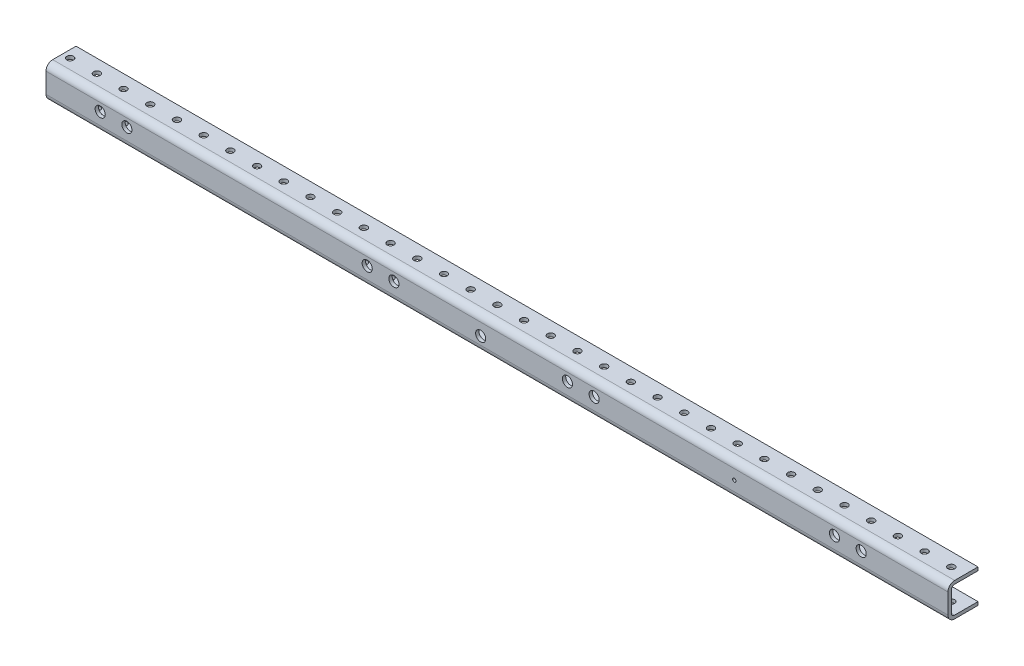
from build123d import *

# Parameters (mm, degrees)
SKETCH1_W          = 889
SKETCH1_H          = 31.75
EXTRUDE1_DEPTH     = 28.575
EXTRUDE2_REACH     = 891.702
SKETCH2_W          = 25.4
SKETCH2_H          = 25.4
HOLE1_D            = 6.35
HOLE1_DEPTH        = 3.175
LPATTERN1_COUNT    = 35
LPATTERN1_PITCH    = 25.4
HOLE2_D            = 9.652
LPATTERN2_COUNT    = 12
LPATTERN2_PITCH    = 25.4
HOLE3_D            = 9.652
HOLE4_D            = 9.652
LPATTERN3_COUNT    = 12
LPATTERN3_PITCH    = 25.4
HOLE5_D            = 3.175
HOLE6_D            = 6.35
LPATTERN4_COUNT    = 35
LPATTERN4_PITCH    = 25.4
FILLET1_R          = 3.175
FILLET2_R          = 3.175
FILLET3_R          = 6.35
FILLET4_R          = 6.35
SKETCH16_W         = 47.760071232
SKETCH16_H         = 71.504803879
CUT_EXTRUDE2_DEPTH = 55


with BuildPart() as part:
    # Sketch1 → Extrude1 (new body)
    with BuildSketch(Plane.XY.offset(3.175)):
        with Locations((428.480011997, 8.672957166)):
            Rectangle(SKETCH1_W, SKETCH1_H)
    extrude(amount=-EXTRUDE1_DEPTH)

    # Sketch2 → Extrude2 (cut, up to next)
    with BuildSketch(Plane.ZY.offset(16.019988003), mode=Mode.PRIVATE) as extrude2_sk1:
        with Locations((-12.7, 8.672957166)):
            Rectangle(SKETCH2_W, SKETCH2_H)
    extrude2_tool1 = extrude(extrude2_sk1.sketch, amount=-EXTRUDE2_REACH, mode=Mode.PRIVATE) & part.part
    add(extrude2_tool1.solids().sort_by_distance((-16.019988, 8.672957, -12.7))[0], mode=Mode.SUBTRACT)

    # Hole1
    with Locations(Plane(origin=(0, 24.547957166, 0), x_dir=(-1, 0, 0), z_dir=(0, 1, 0))):
        with Locations((3.319988003, -12.7)):
            hole1 = Hole(HOLE1_D / 2, depth=HOLE1_DEPTH)

    # LPattern1: Hole1 ×35
    with Locations(*[(i * LPATTERN1_PITCH, 0, 0) for i in range(1, LPATTERN1_COUNT)]):
        add(hole1, mode=Mode.SUBTRACT)

    # Hole2 (through all)
    with Locations(Plane.XY.offset(3.175)):
        with Locations((66.530011997, 10.577957166)):
            hole2 = Hole(HOLE2_D / 2)

    # LPattern2: Hole2 ×12, 8 skipped
    with Locations(*[(i * LPATTERN2_PITCH, 0, 0) for i in range(1, LPATTERN2_COUNT) if i not in (2, 3, 4, 5, 6, 7, 8, 9)]):
        add(hole2, mode=Mode.SUBTRACT)

    # Hole3 (through all)
    with Locations(Plane.XY.offset(3.175)):
        with Locations((428.480011997, 6.767957166)):
            Hole(HOLE3_D / 2)

    # Hole4 (through all)
    with Locations(Plane.XY.offset(3.175)):
        with Locations((511.030011997, 10.577957166)):
            hole4 = Hole(HOLE4_D / 2)

    # LPattern3: Hole4 ×12, 8 skipped
    with Locations(*[(i * LPATTERN3_PITCH, 0, 0) for i in range(1, LPATTERN3_COUNT) if i not in (2, 3, 4, 5, 6, 7, 8, 9)]):
        add(hole4, mode=Mode.SUBTRACT)

    # Hole5 (through all)
    with Locations(Plane.XY.offset(3.175)):
        with Locations((669.780011997, 8.672957166)):
            Hole(HOLE5_D / 2)

    # Hole6 (through all)
    with Locations(Plane(origin=(0, -4.027042834, 0), x_dir=(-1, 0, 0), z_dir=(0, 1, 0))):
        with Locations((3.319988003, -12.7)):
            hole6 = Hole(HOLE6_D / 2)

    # LPattern4: Hole6 ×35
    with Locations(*[(i * LPATTERN4_PITCH, 0, 0) for i in range(1, LPATTERN4_COUNT)]):
        add(hole6, mode=Mode.SUBTRACT)

    # Fillet1
    fillet1_edges = [part.edges().sort_by_distance(p)[0] for p in [
        (428.480011997, 21.372957166, 0),
    ]]
    fillet(fillet1_edges, radius=FILLET1_R)

    # Fillet2
    fillet2_edges = [part.edges().sort_by_distance(p)[0] for p in [
        (428.480011997, -4.027042834, 0),
    ]]
    fillet(fillet2_edges, radius=FILLET2_R)

    # Fillet3
    fillet3_edges = [part.edges().sort_by_distance(p)[0] for p in [
        (428.480011997, -7.202042834, 3.175),
    ]]
    fillet(fillet3_edges, radius=FILLET3_R)

    # Fillet4
    fillet4_edges = [part.edges().sort_by_distance(p)[0] for p in [
        (428.480011997, 24.547957166, 3.175),
    ]]
    fillet(fillet4_edges, radius=FILLET4_R)

    # Sketch16 → Cut-Extrude2 (cut)
    with BuildSketch(Plane(origin=(0, 24.547957166, 0), x_dir=(1, 0, 0), z_dir=(0, 1, 0))):
        with Locations((-8.900023619, -10.352401939)):
            Rectangle(SKETCH16_W, SKETCH16_H)
    extrude(amount=-CUT_EXTRUDE2_DEPTH, mode=Mode.SUBTRACT)


solid = part.part
